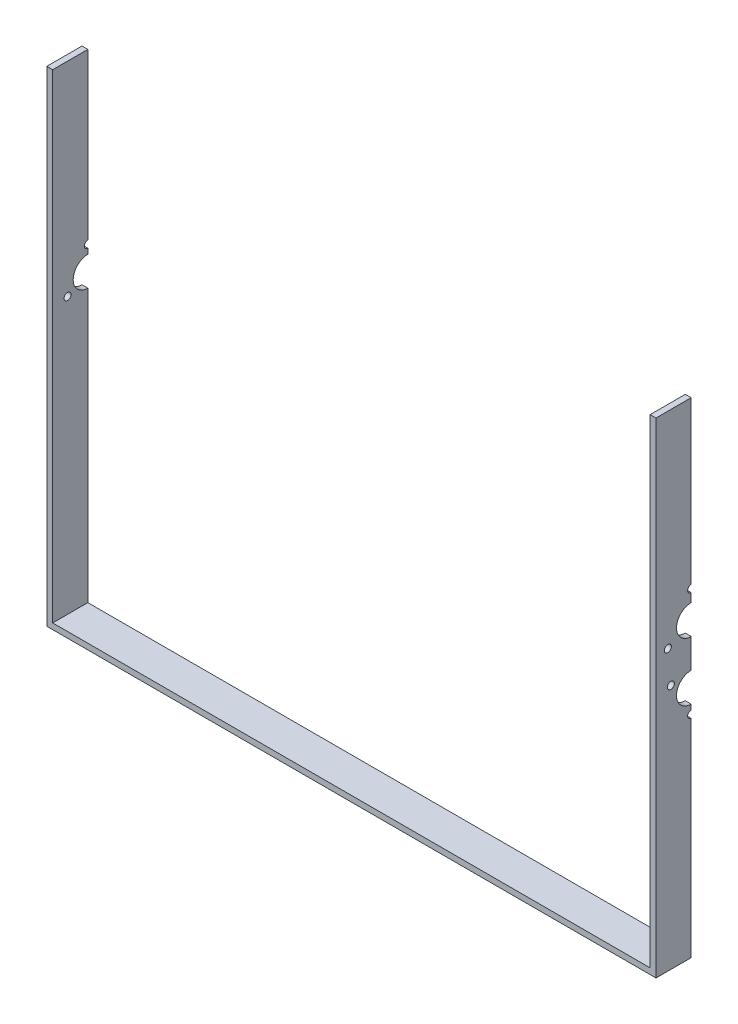
from build123d import *

# Parameters (mm, degrees)
EXTRUDE_1_DEPTH     = 30
CUT_EXTRUDE_1_REACH = 522
SKETCH_2_R          = 12.5
CUT_EXTRUDE_2_REACH = 522
SKETCH_3_R          = 12.5
SKETCH_5_R          = 3
CUT_EXTRUDE_3_DEPTH = 5
SKETCH_6_R          = 3
CUT_EXTRUDE_5_DEPTH = 5
SKETCH_7_R          = 3
CUT_EXTRUDE_6_DEPTH = 5


with BuildPart() as part:
    # 草图1 → Extrude 1 (new body)
    with BuildSketch(Plane.XY):
        Polygon((-255, 204.5), (-255, -204.5), (255, -204.5), (255, 204.5), (260, 204.5), (260, -209.5), (-260, -209.5), (-260, 204.5), align=None)
    extrude(amount=EXTRUDE_1_DEPTH)

    # 草图2 → 切除-拉伸1 (cut, up to next)
    with BuildSketch(Plane.ZY.offset(260), mode=Mode.PRIVATE) as cut_extrude_1_sk1:
        with Locations((0, 40.5)):
            Circle(SKETCH_2_R)
    cut_extrude_1_tool1 = extrude(cut_extrude_1_sk1.sketch, amount=-CUT_EXTRUDE_1_REACH, mode=Mode.PRIVATE) & part.part
    add(cut_extrude_1_tool1.solids().sort_by_distance((-260, 40.5, 0))[0], mode=Mode.SUBTRACT)

    # 草图3 → 切除-拉伸2 (cut, up to next)
    with BuildSketch(Plane(origin=(260, 0, 0), x_dir=(0, 0, -1), z_dir=(1, 0, 0)), mode=Mode.PRIVATE) as cut_extrude_2_sk1:
        with Locations((0, 40.5)):
            Circle(SKETCH_3_R)
    cut_extrude_2_tool1 = extrude(cut_extrude_2_sk1.sketch, amount=-CUT_EXTRUDE_2_REACH, mode=Mode.PRIVATE) & part.part
    add(cut_extrude_2_tool1.solids().sort_by_distance((260, 40.5, 0))[0], mode=Mode.SUBTRACT)
    # 草图3 → 切除-拉伸2 (cut, up to next)
    with BuildSketch(Plane(origin=(260, 0, 0), x_dir=(0, 0, -1), z_dir=(1, 0, 0)), mode=Mode.PRIVATE) as cut_extrude_2_sk2:
        with Locations((0, -9.5)):
            Circle(SKETCH_3_R)
    cut_extrude_2_tool2 = extrude(cut_extrude_2_sk2.sketch, amount=-CUT_EXTRUDE_2_REACH, mode=Mode.PRIVATE) & part.part
    add(cut_extrude_2_tool2.solids().sort_by_distance((260, -9.5, 0))[0], mode=Mode.SUBTRACT)

    # 草图5 → 切除-拉伸3 (cut)
    with BuildSketch(Plane(origin=(260, 0, 0), x_dir=(0, 0, -1), z_dir=(1, 0, 0))):
        with Locations((0, -29.5)):
            Circle(SKETCH_5_R)
        with Locations((-17.320508076, 0.5)):
            Circle(SKETCH_5_R)
    extrude(amount=-CUT_EXTRUDE_3_DEPTH, mode=Mode.SUBTRACT)

    # 草图6 → 切除-拉伸5 (cut)
    with BuildSketch(Plane.ZY.offset(260)):
        with Locations((0, 60.5)):
            Circle(SKETCH_6_R)
        with Locations((17.320508076, 30.5)):
            Circle(SKETCH_6_R)
    extrude(amount=-CUT_EXTRUDE_5_DEPTH, mode=Mode.SUBTRACT)

    # 草图7 → 切除-拉伸6 (cut)
    with BuildSketch(Plane(origin=(260, 0, 0), x_dir=(0, 0, -1), z_dir=(1, 0, 0))):
        with Locations((0, 63.5)):
            Circle(SKETCH_7_R)
        with Locations((-19.918584287, 29)):
            Circle(SKETCH_7_R)
    extrude(amount=-CUT_EXTRUDE_6_DEPTH, mode=Mode.SUBTRACT)


solid = part.part
